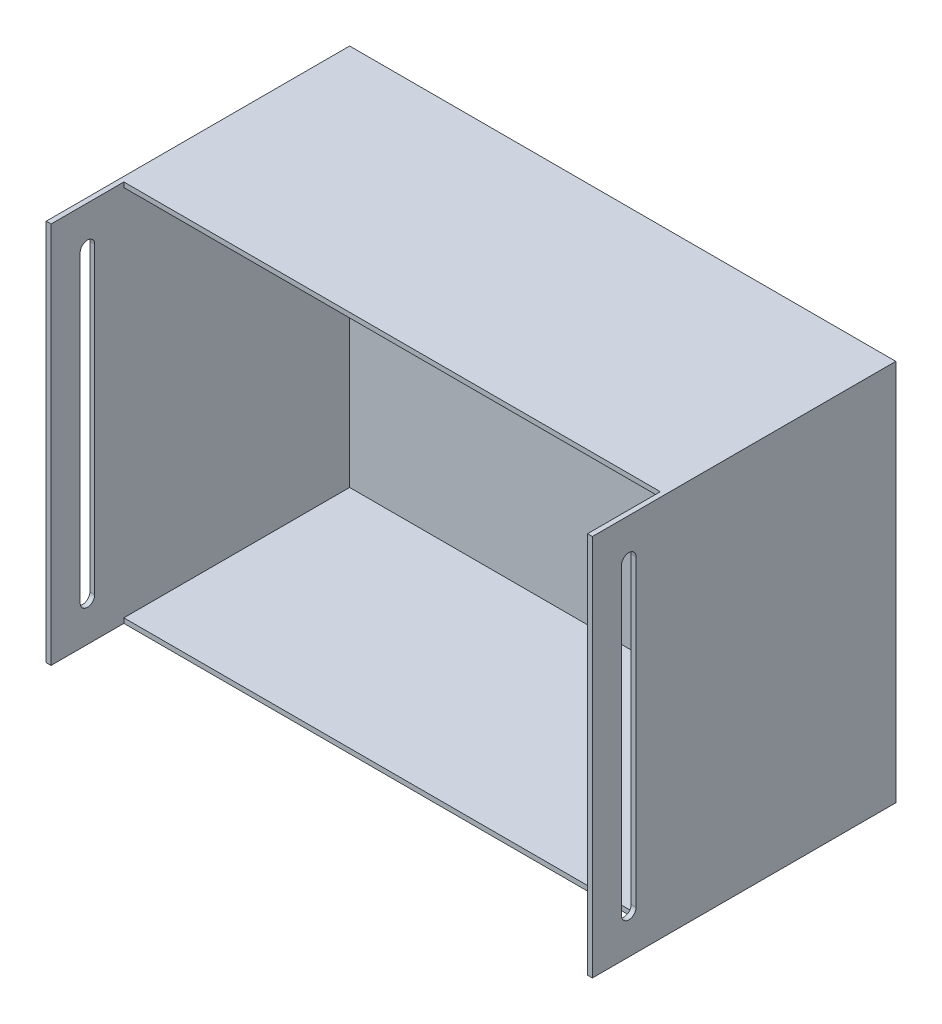
from build123d import *

# Parameters (mm, degrees)
SKETCH_1_W          = 450
SKETCH_1_H          = 315
EXTRUDE_1_DEPTH     = 250
SHELL_3_T           = -4
SKETCH_4_W          = 442
SKETCH_4_H          = 60
CUT_EXTRUDE_1_DEPTH = 316
CUT_EXTRUDE_2_DEPTH = 451


with BuildPart() as part:
    # 草图1 → 凸台-拉伸1 (new body)
    with BuildSketch(Plane.XY):
        Rectangle(SKETCH_1_W, SKETCH_1_H)
    extrude(amount=-EXTRUDE_1_DEPTH)

    # 抽壳3
    shell_3_openings = [part.faces().sort_by_distance(p)[0] for p in [
        (0, 0, 0),
    ]]
    offset(amount=SHELL_3_T, openings=shell_3_openings, kind=Kind.INTERSECTION)

    # 草图4 → 切除-拉伸1 (cut, through all)
    with BuildSketch(Plane.XZ.offset(157.5)):
        with Locations((0, -30)):
            Rectangle(SKETCH_4_W, SKETCH_4_H)
    extrude(amount=-CUT_EXTRUDE_1_DEPTH, mode=Mode.SUBTRACT)

    # 草图5 → 切除-拉伸2 (cut, through all)
    with BuildSketch(Plane(origin=(225, 0, 0), x_dir=(0, 0, -1), z_dir=(1, 0, 0))):
        with BuildLine():
            Line((36, 125), (36, -125))
            ThreePointArc((36, -125), (30, -131), (24, -125))
            Line((24, -125), (24, 125))
            ThreePointArc((24, 125), (30, 131), (36, 125))
        make_face()
    extrude(amount=-CUT_EXTRUDE_2_DEPTH, mode=Mode.SUBTRACT)


solid = part.part
